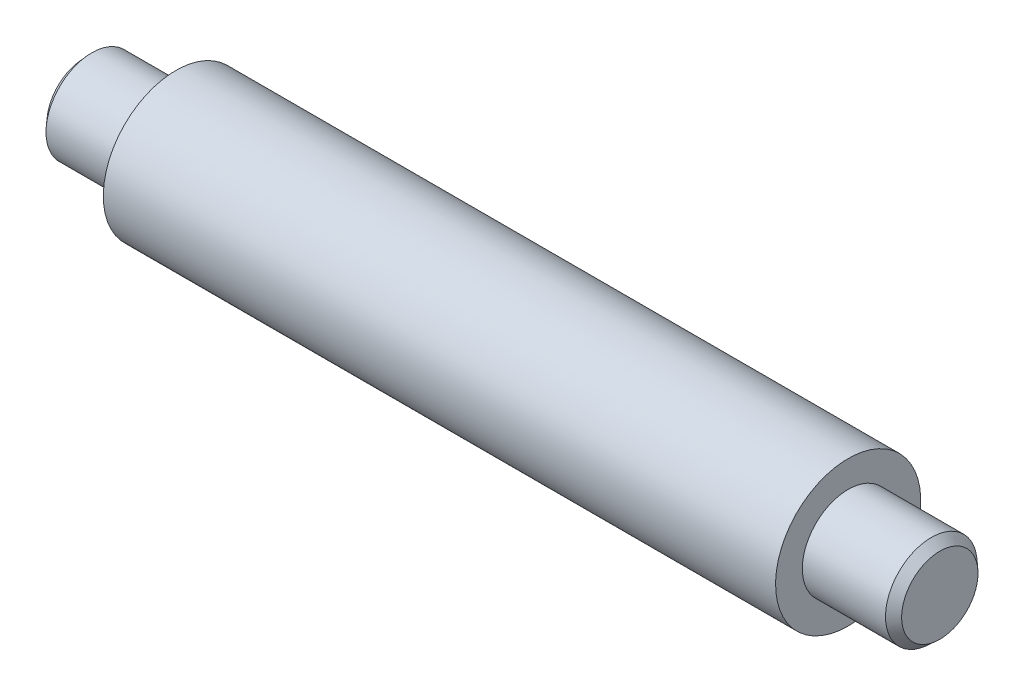
from build123d import *

# Parameters (mm, degrees)
PAH1_SIZE         = 5
PAH1_SIZE2        = 5.553062574
PAH1_PART_2_SIZE  = 5
PAH1_PART_2_SIZE2 = 5.553062574


with BuildPart() as part:
    # Çizim2 → Döndür1 (revolve)
    with BuildSketch(Plane.XY):
        Polygon((0, 30), (560, 30), (560, 60), (500, 60), (500, 77.5), (60, 77.5), (60, 60), (0, 60), align=None)
    revolve(axis=Axis((0, 30, 0), (1, 0, 0)))

    # Pah1
    pah1_edges = [part.edges().sort_by_distance(p)[0] for p in [
        (0, 0, 0),
    ]]
    pah1_side = [part.faces().sort_by_distance(p)[0] for p in [
        (30, 0, 0),
    ]]
    chamfer(pah1_edges, length=PAH1_SIZE, length2=PAH1_SIZE2, reference=pah1_side[0])

    # Pah1 part 2
    pah1_part_2_edges = [part.edges().sort_by_distance(p)[0] for p in [
        (560, 0, 0),
    ]]
    pah1_part_2_side = [part.faces().sort_by_distance(p)[0] for p in [
        (560, 30, 0),
    ]]
    chamfer(pah1_part_2_edges, length=PAH1_PART_2_SIZE, length2=PAH1_PART_2_SIZE2, reference=pah1_part_2_side[0])


solid = part.part
